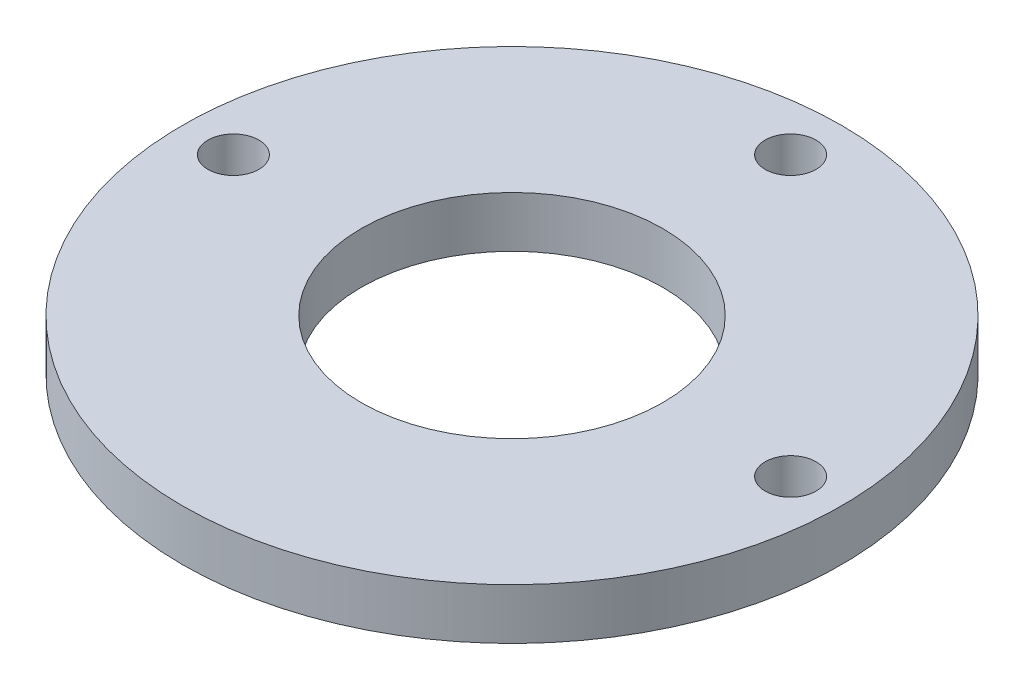
from build123d import *

# Parameters (mm, degrees)
SKETCH1_R           = 41.075
SKETCH1_R_2         = 3.175
SKETCH1_R_3         = 18.796
BOSS_EXTRUDE2_DEPTH = 6.35


with BuildPart() as part:
    # Sketch1 → Boss-Extrude2 (new body)
    with BuildSketch(Plane(origin=(0, 0, 0), x_dir=(1, 0, 0), z_dir=(0, 1, 0))):
        Circle(SKETCH1_R)
        with Locations((0, 34.725)):
            Circle(SKETCH1_R_2, mode=Mode.SUBTRACT)
        with Locations((34.725, 0)):
            Circle(SKETCH1_R_2, mode=Mode.SUBTRACT)
        with Locations((-34.725, 0)):
            Circle(SKETCH1_R_2, mode=Mode.SUBTRACT)
        Circle(SKETCH1_R_3, mode=Mode.SUBTRACT)
    extrude(amount=BOSS_EXTRUDE2_DEPTH)


solid = part.part
